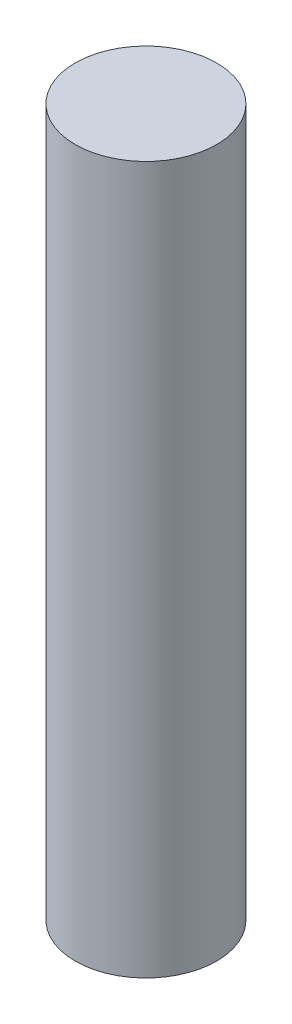
from build123d import *

# Parameters (mm, degrees)
CROQUIS1_R              = 5
SALIENTE_EXTRUIR1_DEPTH = 50


with BuildPart() as part:
    # Croquis1 → Saliente-Extruir1 (new body)
    with BuildSketch(Plane(origin=(0, 0, 0), x_dir=(1, 0, 0), z_dir=(0, 1, 0))):
        Circle(CROQUIS1_R)
    extrude(amount=SALIENTE_EXTRUIR1_DEPTH)


solid = part.part
